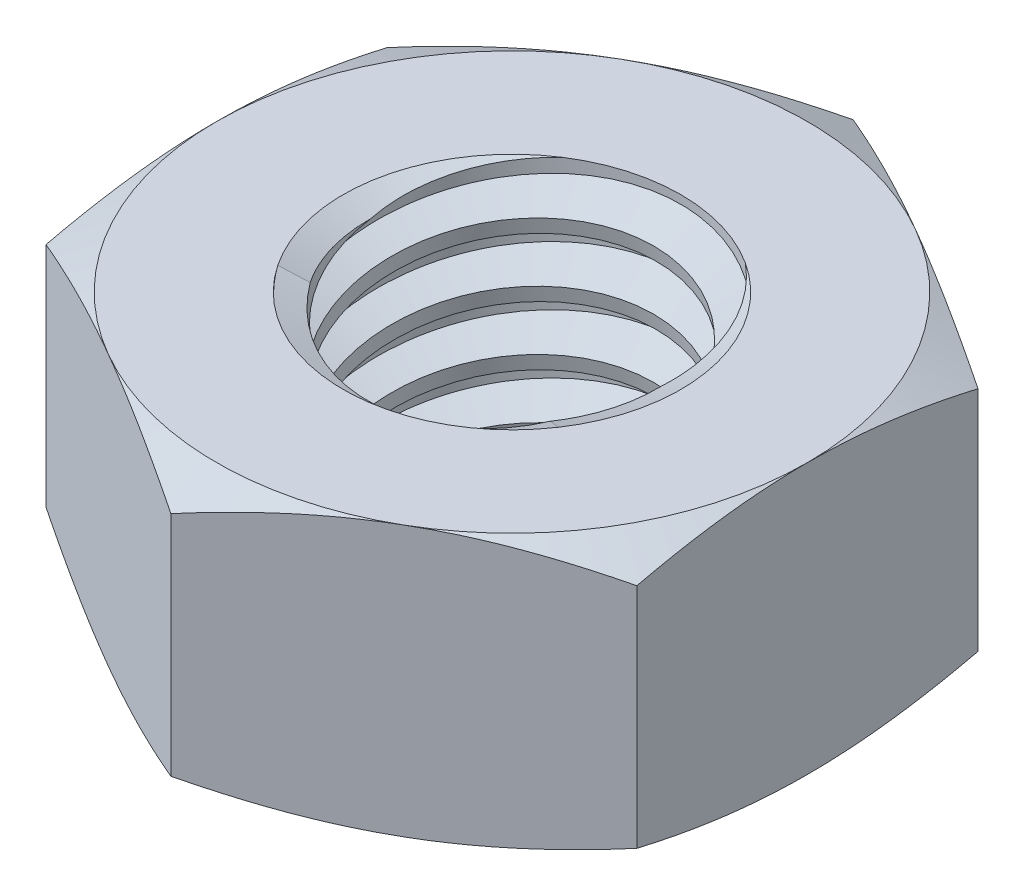
from build123d import *

# Parameters (mm, degrees)
EXTRUDE1_DEPTH       = 1.6
SKETCH2_W            = 2
SKETCH2_H            = 3.2
LPATTERN1_COUNT      = 5
LPATTERN1_PITCH      = 0.7
LPATTERN1_COUNT_DIR2 = 2
LPATTERN1_PITCH_DIR2 = 0.7


with BuildPart() as part:
    # Sketch1 → Extrude1 (new, symmetric)
    with BuildSketch(Plane(origin=(0, 0, 0), x_dir=(1, 0, 0), z_dir=(0, 1, 0))):
        Polygon((0, 4.041451884), (-3.5, 2.020725942), (-3.5, -2.020725942), (0, -4.041451884), (3.5, -2.020725942), (3.5, 2.020725942), align=None)
    extrude(amount=EXTRUDE1_DEPTH, both=True)

    # Sketch4 → Cut-Revolve2 (revolve, cut)
    with BuildSketch(Plane(origin=(0, 0, 0), x_dir=(0, 0, -1), z_dir=(1, 0, 0))):
        Polygon((0, 1.6), (2, 1.6), (1.679577111, 1.450584353), (1.679577111, -1.450584353), (2, -1.6), (0, -1.6), align=None)
    revolve(axis=Axis((0, 1.6, 0), (0, 1, 0)), mode=Mode.SUBTRACT)


with BuildPart() as body_2:
    # Sketch2 → Revolve1 (revolve)
    with BuildSketch(Plane(origin=(0, 0, 0), x_dir=(0, 0, -1), z_dir=(1, 0, 0))):
        with Locations((1, 0)):
            Rectangle(SKETCH2_W, SKETCH2_H)
    revolve(axis=Axis((0, -3.6, 0), (0, 1, 0)))

    # Sketch3 → Cut-Revolve1 (revolve, cut)
    with BuildSketch(Plane(origin=(0, 0, 0), x_dir=(0, 0, -1), z_dir=(1, 0, 0))):
        Polygon((2.015083279, 1.513809834), (2.120666232, 0.910478673), (1.709743669, 1.060641574), (1.679577111, 1.233021905), align=None)
    cut_revolve1 = revolve(axis=Axis((0, 1.6, 0.13120342), (0, -0.9850304671557042, -0.1723803317522485)), mode=Mode.SUBTRACT)

    # LPattern1: Cut-Revolve1 5 × 2
    with Locations(*[Vector(0, -1, 0) * (i * LPATTERN1_PITCH) + Vector(0, 1, 0) * (j * LPATTERN1_PITCH_DIR2) for i in range(LPATTERN1_COUNT) for j in range(LPATTERN1_COUNT_DIR2) if (i, j) != (0, 0)]):
        add(cut_revolve1, mode=Mode.SUBTRACT)


with BuildPart() as part_1:
    add(part.part)

    # Combine1: cut body 2
    add(body_2.part, mode=Mode.SUBTRACT)

    # Sketch5 → Cut-Revolve3 (revolve, cut)
    with BuildSketch(Plane(origin=(0, 0, 0), x_dir=(0, 0, -1), z_dir=(1, 0, 0))):
        Polygon((0, -1.6), (3.5, -1.6), (4.041451884, -1.34751684), (4.041451884, 1.34751684), (3.5, 1.6), (0, 1.6), (0, 2.87), (5.311451884, 2.87), (5.311451884, -2.87), (0, -2.87), align=None)
    revolve(axis=Axis((0, -1.6, 0), (0, 1, 0)), mode=Mode.SUBTRACT)


solid = part_1.part
